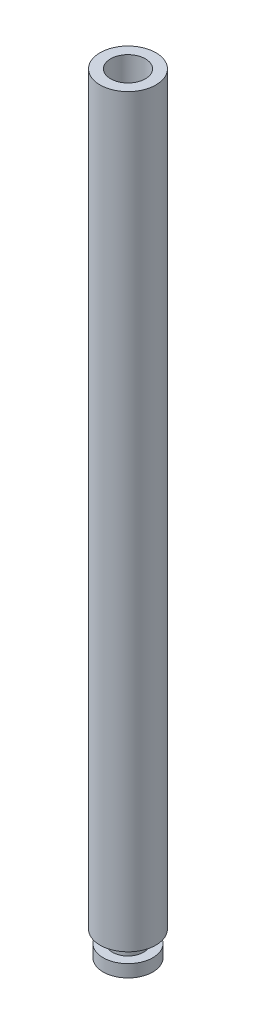
from build123d import *

# Parameters (mm, degrees)
SKETCH1_R           = 2.25
BOSS_EXTRUDE1_DEPTH = 60
SKETCH1_3_R         = 1.375
BOSS_EXTRUDE2_DEPTH = 1
SKETCH5_R           = 1.25
BOSS_EXTRUDE3_DEPTH = 1
SKETCH6_R           = 2
BOSS_EXTRUDE4_DEPTH = 1
SKETCH12_R          = 1.4
CUT_EXTRUDE1_DEPTH  = 15


with BuildPart() as part:
    # Sketch1 → Boss-Extrude1 (new body)
    with BuildSketch(Plane(origin=(0, 0, 0), x_dir=(1, 0, 0), z_dir=(0, 1, 0))):
        with Locations((-0.522013312, 0.511138034)):
            Circle(SKETCH1_R)
    extrude(amount=BOSS_EXTRUDE1_DEPTH)

    # Sketch1_3 → Boss-Extrude2 (add)
    with BuildSketch(Plane(origin=(0, 0, 0), x_dir=(1, 0, 0), z_dir=(0, 1, 0))):
        with Locations((-0.522013312, 0.511138034)):
            Circle(SKETCH1_3_R)
    extrude(amount=BOSS_EXTRUDE2_DEPTH)

    # Sketch5 → Boss-Extrude3 (add)
    with BuildSketch(Plane.XZ):
        with Locations((-0.522013312, -0.511138034)):
            Circle(SKETCH5_R)
    extrude(amount=BOSS_EXTRUDE3_DEPTH)

    # Sketch6 → Boss-Extrude4 (add)
    with BuildSketch(Plane.XZ.offset(1)):
        with Locations((-0.522013312, -0.511138034)):
            Circle(SKETCH6_R)
    extrude(amount=BOSS_EXTRUDE4_DEPTH)

    # Sketch12 → Cut-Extrude1 (cut)
    with BuildSketch(Plane(origin=(0, 60, 0), x_dir=(1, 0, 0), z_dir=(0, 1, 0))):
        with Locations((-0.522013312, 0.511138034)):
            Circle(SKETCH12_R)
    extrude(amount=-CUT_EXTRUDE1_DEPTH, mode=Mode.SUBTRACT)


solid = part.part
